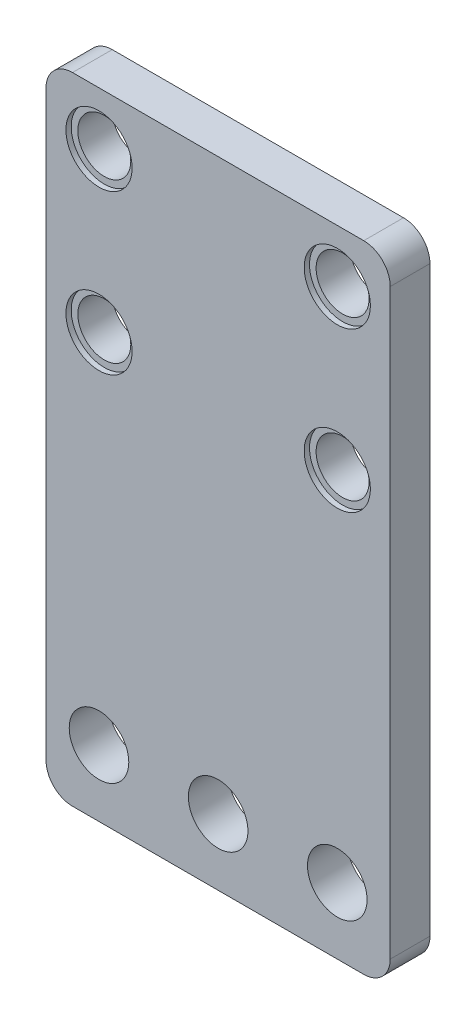
from build123d import *

# Parameters (mm, degrees)
ESQUISSE1_W                  = 26
ESQUISSE1_H                  = 48
BOSS_EXTRU_1_DEPTH           = 3
ESQUISSE2_R                  = 2
ENL_V_MAT_EXTRU_1_DEPTH      = 1
ENL_V_MAT_EXTRU_1_DEPTH_BACK = 4
ESQUISSE3_R                  = 2.25
ENL_V_MAT_EXTRU_2_DEPTH      = 1
ENL_V_MAT_EXTRU_2_DEPTH_BACK = 4
ESQUISSE4_R                  = 2.5
ENL_V_MAT_EXTRU_3_DEPTH      = 0.4
CONG_1_R                     = 2


with BuildPart() as part:
    # Esquisse1 → Boss.-Extru.1 (new body)
    with BuildSketch(Plane.XY):
        with Locations((13, 24)):
            Rectangle(ESQUISSE1_W, ESQUISSE1_H)
    extrude(amount=BOSS_EXTRU_1_DEPTH)

    # Esquisse2 → Enlèv. mat.-Extru.1 (cut, two sides)
    with BuildSketch(Plane.XY.offset(3)) as enl_v_mat_extru_1_sk:
        with Locations((4, 44)):
            Circle(ESQUISSE2_R)
        with Locations((4, 32)):
            Circle(ESQUISSE2_R)
        with Locations((22, 32)):
            Circle(ESQUISSE2_R)
        with Locations((22, 44)):
            Circle(ESQUISSE2_R)
    extrude(amount=ENL_V_MAT_EXTRU_1_DEPTH, mode=Mode.SUBTRACT)
    extrude(enl_v_mat_extru_1_sk.sketch, amount=-ENL_V_MAT_EXTRU_1_DEPTH_BACK, mode=Mode.SUBTRACT)

    # Esquisse3 → Enlèv. mat.-Extru.2 (cut, two sides)
    with BuildSketch(Plane.XY.offset(3)) as enl_v_mat_extru_2_sk:
        with Locations((13, 5)):
            Circle(ESQUISSE3_R)
        with Locations((4, 5)):
            Circle(ESQUISSE3_R)
        with Locations((22, 5)):
            Circle(ESQUISSE3_R)
    extrude(amount=ENL_V_MAT_EXTRU_2_DEPTH, mode=Mode.SUBTRACT)
    extrude(enl_v_mat_extru_2_sk.sketch, amount=-ENL_V_MAT_EXTRU_2_DEPTH_BACK, mode=Mode.SUBTRACT)

    # Esquisse4 → Enlèv. mat.-Extru.3 (cut)
    with BuildSketch(Plane.XY.offset(3)):
        with Locations((4, 32)):
            Circle(ESQUISSE4_R)
        with Locations((22, 32)):
            Circle(ESQUISSE4_R)
        with Locations((22, 44)):
            Circle(ESQUISSE4_R)
        with Locations((4, 44)):
            Circle(ESQUISSE4_R)
    extrude(amount=-ENL_V_MAT_EXTRU_3_DEPTH, mode=Mode.SUBTRACT)

    # Congé1
    cong_1_edges = [part.edges().sort_by_distance(p)[0] for p in [
        (0, 48, 1.5),
        (26, 48, 1.5),
        (26, 0, 1.5),
        (0, 0, 1.5),
    ]]
    fillet(cong_1_edges, radius=CONG_1_R)


solid = part.part
